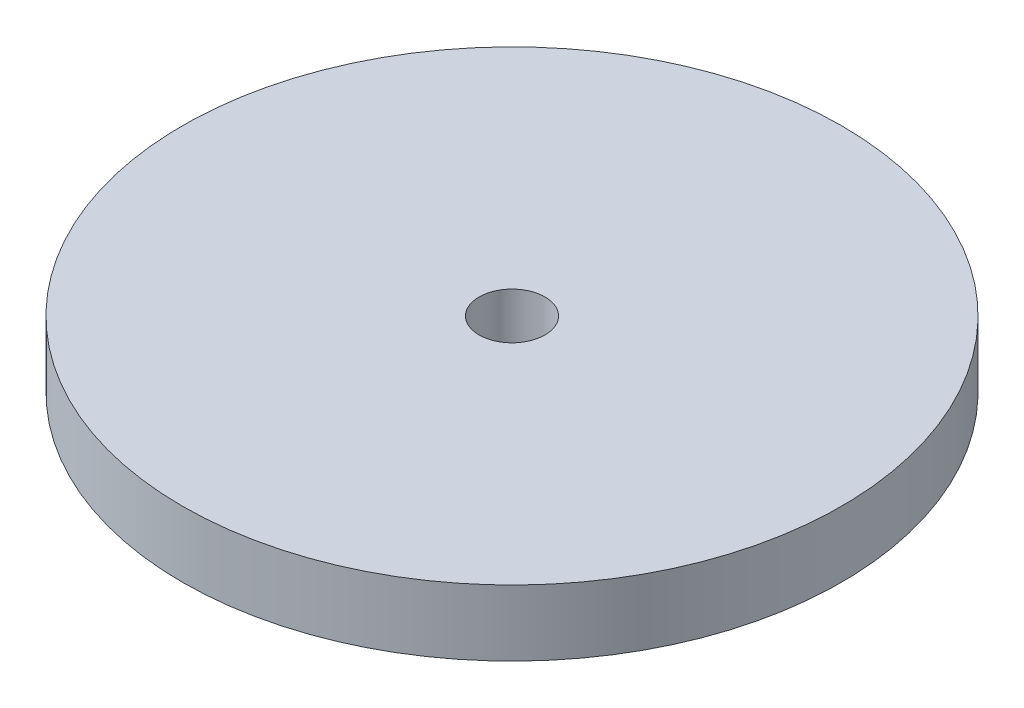
from build123d import *

# Parameters (mm, degrees)
SKETCH1_R           = 50
SKETCH1_R_2         = 5
BOSS_EXTRUDE1_DEPTH = 10


with BuildPart() as part:
    # Sketch1 → Boss-Extrude1 (new body)
    with BuildSketch(Plane(origin=(0, 0, 0), x_dir=(1, 0, 0), z_dir=(0, 1, 0))):
        Circle(SKETCH1_R)
        Circle(SKETCH1_R_2, mode=Mode.SUBTRACT)
    extrude(amount=BOSS_EXTRUDE1_DEPTH)


solid = part.part
